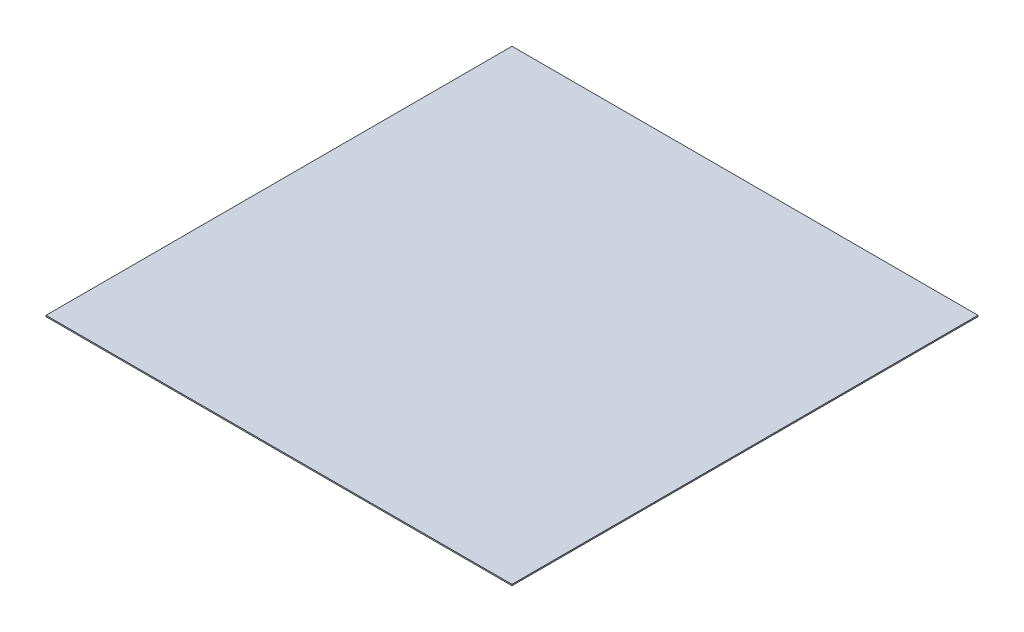
from build123d import *

# Parameters (mm, degrees)
SKETCH1_W           = 150
SKETCH1_H           = 150
BOSS_EXTRUDE1_DEPTH = 0.4


with BuildPart() as part:
    # Sketch1 → Boss-Extrude1 (new body)
    with BuildSketch(Plane(origin=(0, 0, 0), x_dir=(1, 0, 0), z_dir=(0, 1, 0))):
        Rectangle(SKETCH1_W, SKETCH1_H)
    extrude(amount=BOSS_EXTRUDE1_DEPTH)


solid = part.part
